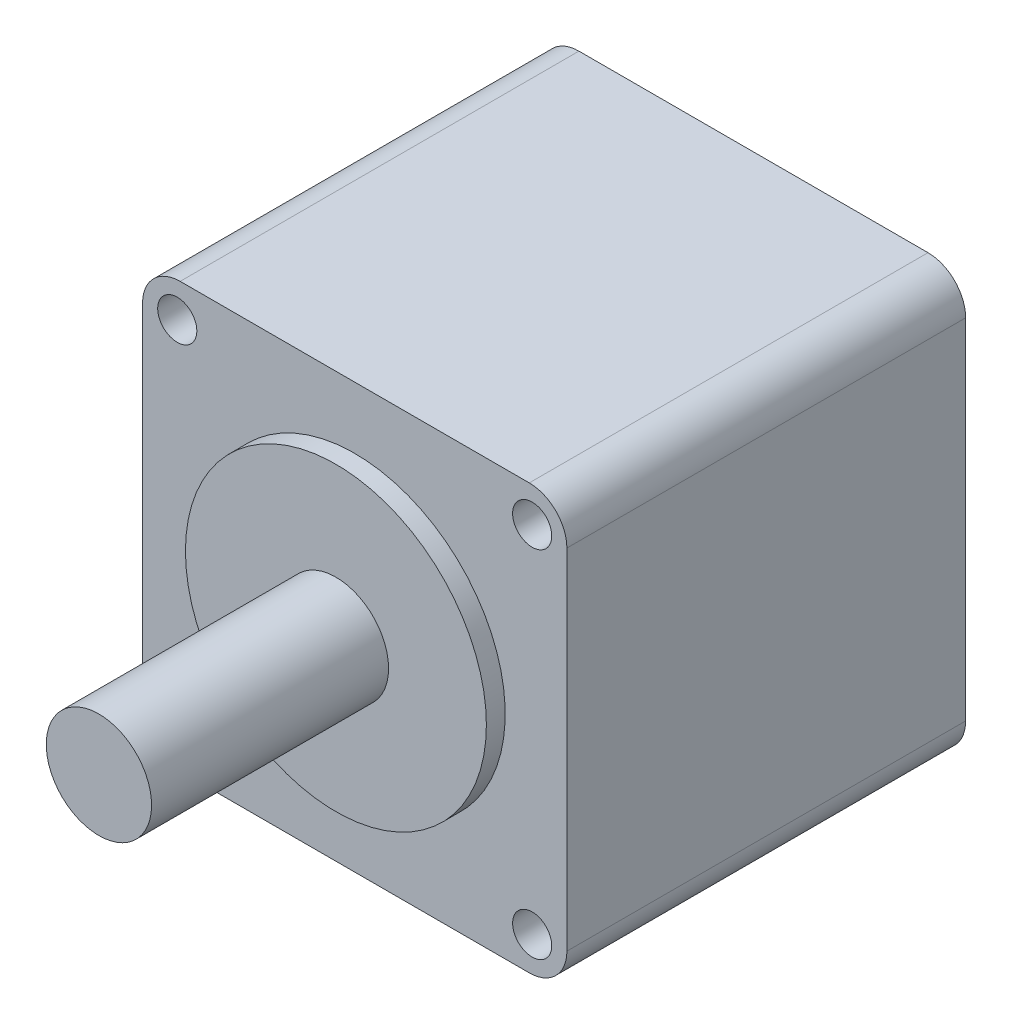
from build123d import *

# Parameters (mm, degrees)
SKETCH_1_W          = 56.4
SKETCH_1_H          = 56.4
EXTRUDE_1_DEPTH     = 53
SKETCH_2_R          = 20
EXTRUDE_2_DEPTH     = 2.5
SKETCH_3_R          = 7
EXTRUDE_3_DEPTH     = 31.5
FILLET_1_R          = 5
SKETCH_4_R          = 2.6
CUT_EXTRUDE_1_DEPTH = 54


with BuildPart() as part:
    # 草图1 → 凸台-拉伸1 (new body)
    with BuildSketch(Plane.XY):
        with Locations((28.2, 28.2)):
            Rectangle(SKETCH_1_W, SKETCH_1_H)
    extrude(amount=EXTRUDE_1_DEPTH)

    # 草图2 → 凸台-拉伸2 (add)
    with BuildSketch(Plane.XY.offset(53)):
        with Locations((28.2, 28.2)):
            Circle(SKETCH_2_R)
    extrude(amount=EXTRUDE_2_DEPTH)

    # 草图3 → 凸台-拉伸3 (add)
    with BuildSketch(Plane.XY.offset(55.5)):
        with Locations((28.2, 28.2)):
            Circle(SKETCH_3_R)
    extrude(amount=EXTRUDE_3_DEPTH)

    # 圆角1
    fillet_1_edges = [part.edges().sort_by_distance(p)[0] for p in [
        (0, 56.4, 26.5),
        (56.4, 56.4, 26.5),
        (56.4, 0, 26.5),
        (0, 0, 26.5),
    ]]
    fillet(fillet_1_edges, radius=FILLET_1_R)

    # 草图4 → 切除-拉伸1 (cut, through all)
    with BuildSketch(Plane.XY.offset(53)):
        with Locations((4.615, 51.785)):
            Circle(SKETCH_4_R)
        with Locations((51.785, 51.785)):
            Circle(SKETCH_4_R)
        with Locations((51.785, 4.615)):
            Circle(SKETCH_4_R)
        with Locations((4.615, 4.615)):
            Circle(SKETCH_4_R)
    extrude(amount=-CUT_EXTRUDE_1_DEPTH, mode=Mode.SUBTRACT)


solid = part.part
